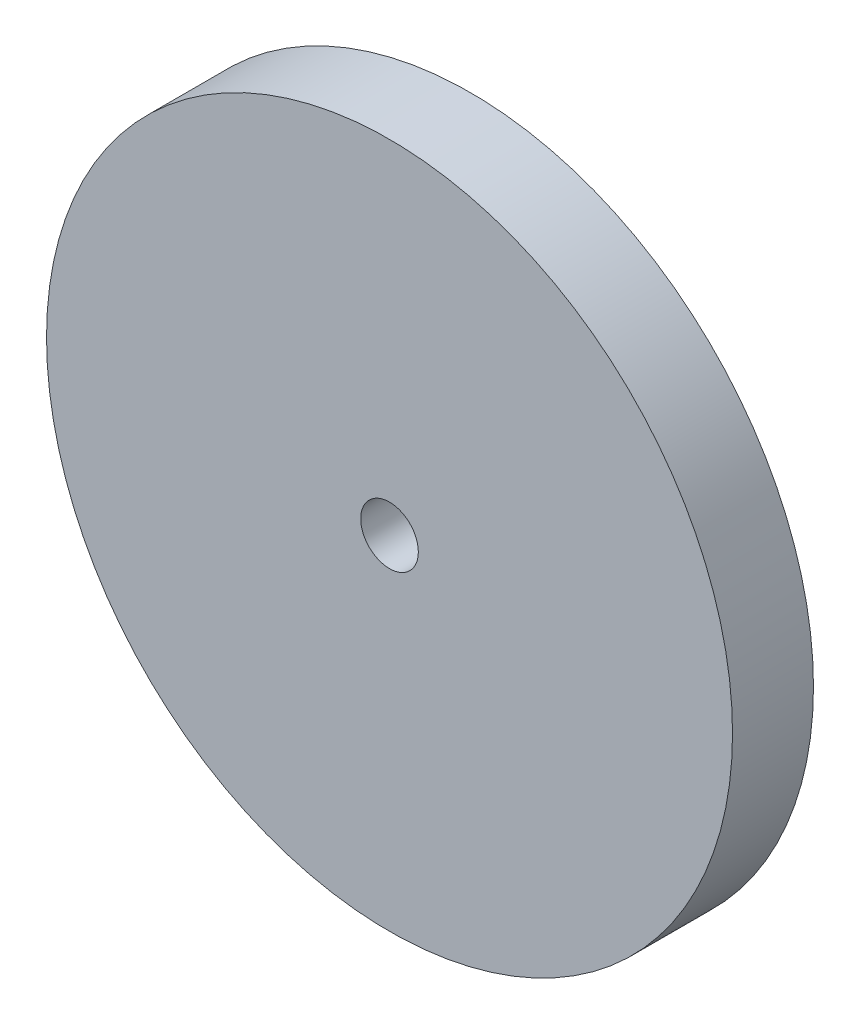
from build123d import *

# Parameters (mm, degrees)
SKETCH1_R           = 25
BOSS_EXTRUDE1_DEPTH = 5.9
CUT_EXTRUDE1_REACH  = 7.9
SKETCH2_R           = 2.1


with BuildPart() as part:
    # Sketch1 → Boss-Extrude1 (new body)
    with BuildSketch(Plane.XY):
        Circle(SKETCH1_R)
    extrude(amount=BOSS_EXTRUDE1_DEPTH)

    # Sketch2 → Cut-Extrude1 (cut, up to next)
    with BuildSketch(Plane.XY.offset(5.9), mode=Mode.PRIVATE) as cut_extrude1_sk1:
        Circle(SKETCH2_R)
    cut_extrude1_tool1 = extrude(cut_extrude1_sk1.sketch, amount=-CUT_EXTRUDE1_REACH, mode=Mode.PRIVATE) & part.part
    add(cut_extrude1_tool1.solids().sort_by_distance((0, 0, 5.9))[0], mode=Mode.SUBTRACT)


solid = part.part
